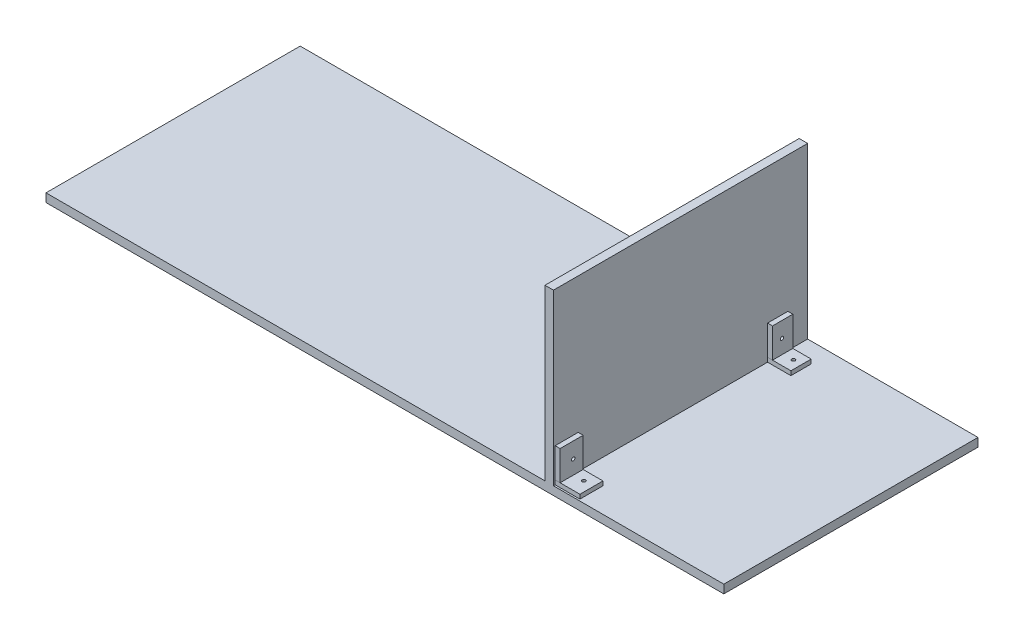
from build123d import *

# Parameters (mm, degrees)
SKETCH1_W                      = 800
SKETCH1_H                      = 300
BOSS_EXTRUDE1_DEPTH            = 10
SKETCH2_W                      = 10
SKETCH2_H                      = 300
BOSS_EXTRUDE2_DEPTH            = 200
SKETCH4_W                      = 29.224082228
SKETCH4_H                      = 27.186820937
BOSS_EXTRUDE4_DEPTH            = 5
SKETCH4_W_2                    = 27.533579719
SKETCH4_H_2                    = 23.943895565
BOSS_EXTRUDE4_2_DEPTH          = 5
SKETCH5_W                      = 5.828784331
SKETCH5_H                      = 27.186820937
BOSS_EXTRUDE5_DEPTH            = 35
SKETCH5_H_2                    = 23.943895565
BOSS_EXTRUDE5_2_DEPTH          = 35
SKETCH7_W                      = 2
SKETCH7_H                      = 15
F_4_0MM_DOWEL_HOLE1_AT_2_COUNT = 2
F_4_0MM_DOWEL_HOLE1_AT_2_PITCH = 247.27458835
SKETCH9_W                      = 2
SKETCH9_H                      = 604.774557392
F_4_0MM_DOWEL_HOLE2_AT_2_COUNT = 2
F_4_0MM_DOWEL_HOLE2_AT_2_PITCH = 246.393174193


with BuildPart() as part:
    # Sketch1 → Boss-Extrude1 (new body)
    with BuildSketch(Plane(origin=(0, 0, 0), x_dir=(1, 0, 0), z_dir=(0, 1, 0))):
        with Locations((-235.513382352, 11.590855644)):
            Rectangle(SKETCH1_W, SKETCH1_H)
    extrude(amount=BOSS_EXTRUDE1_DEPTH)

    # Sketch2 → Boss-Extrude2 (add)
    with BuildSketch(Plane(origin=(0, 10, 0), x_dir=(1, 0, 0), z_dir=(0, 1, 0))):
        with Locations((-41.567634291, 11.590855644)):
            Rectangle(SKETCH2_W, SKETCH2_H)
    extrude(amount=BOSS_EXTRUDE2_DEPTH)


with BuildPart() as body_2:
    # Sketch4 → Boss-Extrude4 (new body)
    with BuildSketch(Plane(origin=(0, 10, 0), x_dir=(1, 0, 0), z_dir=(0, 1, 0))):
        with Locations((-21.955593177, -122.821982617)):
            Rectangle(SKETCH4_W, SKETCH4_H)
    extrude(amount=BOSS_EXTRUDE4_DEPTH)


with BuildPart() as body_3:
    # Sketch4 → Boss-Extrude4 2 (new body)
    with BuildSketch(Plane(origin=(0, 10, 0), x_dir=(1, 0, 0), z_dir=(0, 1, 0))):
        with Locations((-22.800844432, 126.251631239)):
            Rectangle(SKETCH4_W_2, SKETCH4_H_2)
    extrude(amount=BOSS_EXTRUDE4_2_DEPTH)


with BuildPart() as body_4:
    # Sketch5 → Boss-Extrude5 (new body)
    with BuildSketch(Plane(origin=(0, 15, 0), x_dir=(1, 0, 0), z_dir=(0, 1, 0))):
        with Locations((-33.653242126, -122.821982617)):
            Rectangle(SKETCH5_W, SKETCH5_H)
    extrude(amount=BOSS_EXTRUDE5_DEPTH)


with BuildPart() as body_5:
    # Sketch5 → Boss-Extrude5 2 (new body)
    with BuildSketch(Plane(origin=(0, 15, 0), x_dir=(1, 0, 0), z_dir=(0, 1, 0))):
        with Locations((-33.653242126, 126.251631239)):
            Rectangle(SKETCH5_W, SKETCH5_H_2)
    extrude(amount=BOSS_EXTRUDE5_2_DEPTH)


with BuildPart() as f_4_0mm_dowel_hole1_tool:
    # Sketch7 → Ø4.0mm Dowel Hole1 (revolve)
    with BuildSketch(Plane(origin=(-18.687990482, 15, 120.358746082), x_dir=(0, 0, 1), z_dir=(1, 0, 0))):
        with Locations((1, 7.5)):
            Rectangle(SKETCH7_W, SKETCH7_H)
    f_4_0mm_dowel_hole1 = revolve(axis=Axis((-18.687990482, 21.35, 120.358746082), (0, -1, 0)))


with BuildPart() as part_1:
    add(part.part)

    # Ø4.0mm Dowel Hole1: cut by f_4_0mm_dowel_hole1_tool
    add(f_4_0mm_dowel_hole1_tool.part, mode=Mode.SUBTRACT)


with BuildPart() as body_2_1:
    add(body_2.part)

    # Ø4.0mm Dowel Hole1: cut by f_4_0mm_dowel_hole1_tool
    add(f_4_0mm_dowel_hole1_tool.part, mode=Mode.SUBTRACT)


with BuildPart() as f_4_0mm_dowel_hole1_at_2_tool:
    # Ø4.0mm Dowel Hole1 at 2: Ø4.0mm Dowel Hole1 ×2
    with Locations(*[(0, 0, -i * F_4_0MM_DOWEL_HOLE1_AT_2_PITCH) for i in range(1, F_4_0MM_DOWEL_HOLE1_AT_2_COUNT)]):
        add(f_4_0mm_dowel_hole1)


with BuildPart() as part_2:
    add(part_1.part)

    # Ø4.0mm Dowel Hole1 at 2: cut by f_4_0mm_dowel_hole1_at_2_tool
    add(f_4_0mm_dowel_hole1_at_2_tool.part, mode=Mode.SUBTRACT)


with BuildPart() as body_3_1:
    add(body_3.part)

    # Ø4.0mm Dowel Hole1 at 2: cut by f_4_0mm_dowel_hole1_at_2_tool
    add(f_4_0mm_dowel_hole1_at_2_tool.part, mode=Mode.SUBTRACT)


with BuildPart() as f_4_0mm_dowel_hole2_tool:
    # Sketch9 → Ø4.0mm Dowel Hole2 (revolve)
    with BuildSketch(Plane(origin=(-30.73884996, 31.617276176, 120.917654543), x_dir=(0, 0, -1), z_dir=(0, 1, 0))):
        with Locations((1, 302.387278696)):
            Rectangle(SKETCH9_W, SKETCH9_H)
    f_4_0mm_dowel_hole2 = revolve(axis=Axis((-24.38884996, 31.617276176, 120.917654543), (-1, 0, 0)))


with BuildPart() as part_3:
    add(part_2.part)

    # Ø4.0mm Dowel Hole2: cut by f_4_0mm_dowel_hole2_tool
    add(f_4_0mm_dowel_hole2_tool.part, mode=Mode.SUBTRACT)


with BuildPart() as body_4_1:
    add(body_4.part)

    # Ø4.0mm Dowel Hole2: cut by f_4_0mm_dowel_hole2_tool
    add(f_4_0mm_dowel_hole2_tool.part, mode=Mode.SUBTRACT)


with BuildPart() as f_4_0mm_dowel_hole2_at_2_tool:
    # Ø4.0mm Dowel Hole2 at 2: Ø4.0mm Dowel Hole2 ×2
    with Locations(*[(0, 0, -i * F_4_0MM_DOWEL_HOLE2_AT_2_PITCH) for i in range(1, F_4_0MM_DOWEL_HOLE2_AT_2_COUNT)]):
        add(f_4_0mm_dowel_hole2)


with BuildPart() as part_4:
    add(part_3.part)

    # Ø4.0mm Dowel Hole2 at 2: cut by f_4_0mm_dowel_hole2_at_2_tool
    add(f_4_0mm_dowel_hole2_at_2_tool.part, mode=Mode.SUBTRACT)


with BuildPart() as body_5_1:
    add(body_5.part)

    # Ø4.0mm Dowel Hole2 at 2: cut by f_4_0mm_dowel_hole2_at_2_tool
    add(f_4_0mm_dowel_hole2_at_2_tool.part, mode=Mode.SUBTRACT)


solid = Compound([body_2_1.part, body_3_1.part, body_4_1.part, part_4.part, body_5_1.part])
